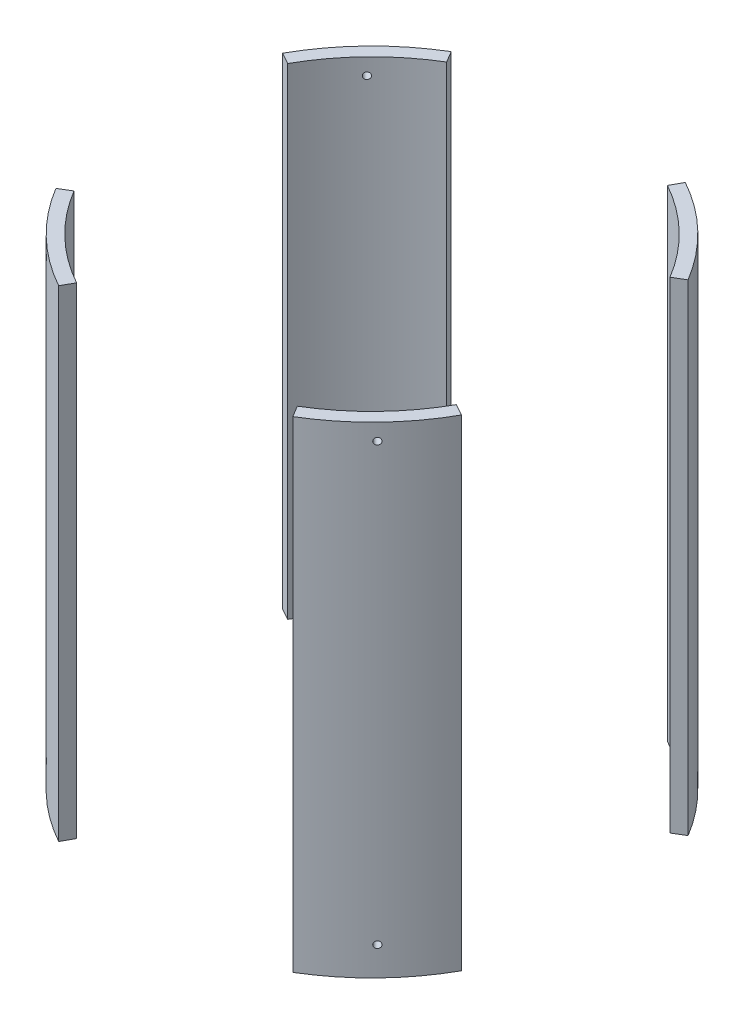
from build123d import *

# Parameters (mm, degrees)
SKETCH2_R               = 88.9
SKETCH2_R_2             = 83.82
BOSS_EXTRUDE1_DEPTH     = 92.862273
CUT_EXTRUDE1_DEPTH      = 93.862273
CUT_EXTRUDE1_DEPTH_BACK = 93.862273
SKETCH5_R               = 1.27
BOLT_HOLES_DEPTH        = 29.911624556
BOLT_PATTERN_COUNT      = 4


with BuildPart() as part:
    # Sketch2 → Boss-Extrude1 (new body, symmetric)
    with BuildSketch(Plane(origin=(0, 0, 0), x_dir=(1, 0, 0), z_dir=(0, 1, 0))):
        Circle(SKETCH2_R)
        Circle(SKETCH2_R_2, mode=Mode.SUBTRACT)
    extrude(amount=BOSS_EXTRUDE1_DEPTH, both=True)

    # Sketch3 → Cut-Extrude1 (cut, two sides)
    with BuildSketch(Plane(origin=(0, 0, 0), x_dir=(1, 0, 0), z_dir=(0, 1, 0))) as cut_extrude1_sk:
        Polygon((169.661755759, -94.300371224), (0, 0), (169.661755759, 101.677593364), align=None)
        Polygon((0, 0), (53.900027233, 96.974944394), (-58.116685864, 96.974944394), align=None)
        Polygon((-123.741299607, 68.777140945), (-123.741299607, -74.157652604), (0, 0), align=None)
        Polygon((-65.840936026, -118.45858783), (0, 0), (70.991745134, -118.45858783), align=None)
    extrude(amount=CUT_EXTRUDE1_DEPTH, mode=Mode.SUBTRACT)
    extrude(cut_extrude1_sk.sketch, amount=-CUT_EXTRUDE1_DEPTH_BACK, mode=Mode.SUBTRACT)

    # Sketch5 → Bolt holes (cut, through all)
    with BuildSketch(Plane(origin=(-56.309218645, 0, 58.175814955), x_dir=(-0.718540152, 0, -0.695485478), z_dir=(0.695485478, 0, -0.718540152))):
        with Locations((-0.02278764, 86.512273)):
            Circle(SKETCH5_R)
        with Locations((-0.02278764, -81.749773)):
            Circle(SKETCH5_R)
    bolt_holes = extrude(amount=-BOLT_HOLES_DEPTH, mode=Mode.SUBTRACT)

    # Bolt pattern: Bolt holes ×4 about axis
    bolt_pattern_axis = Axis((0, 92.862273, 0), (0, 1, 0))
    for i in range(1, BOLT_PATTERN_COUNT):
        add(bolt_holes.rotate(bolt_pattern_axis, i * 360 / BOLT_PATTERN_COUNT), mode=Mode.SUBTRACT)


solid = part.part
